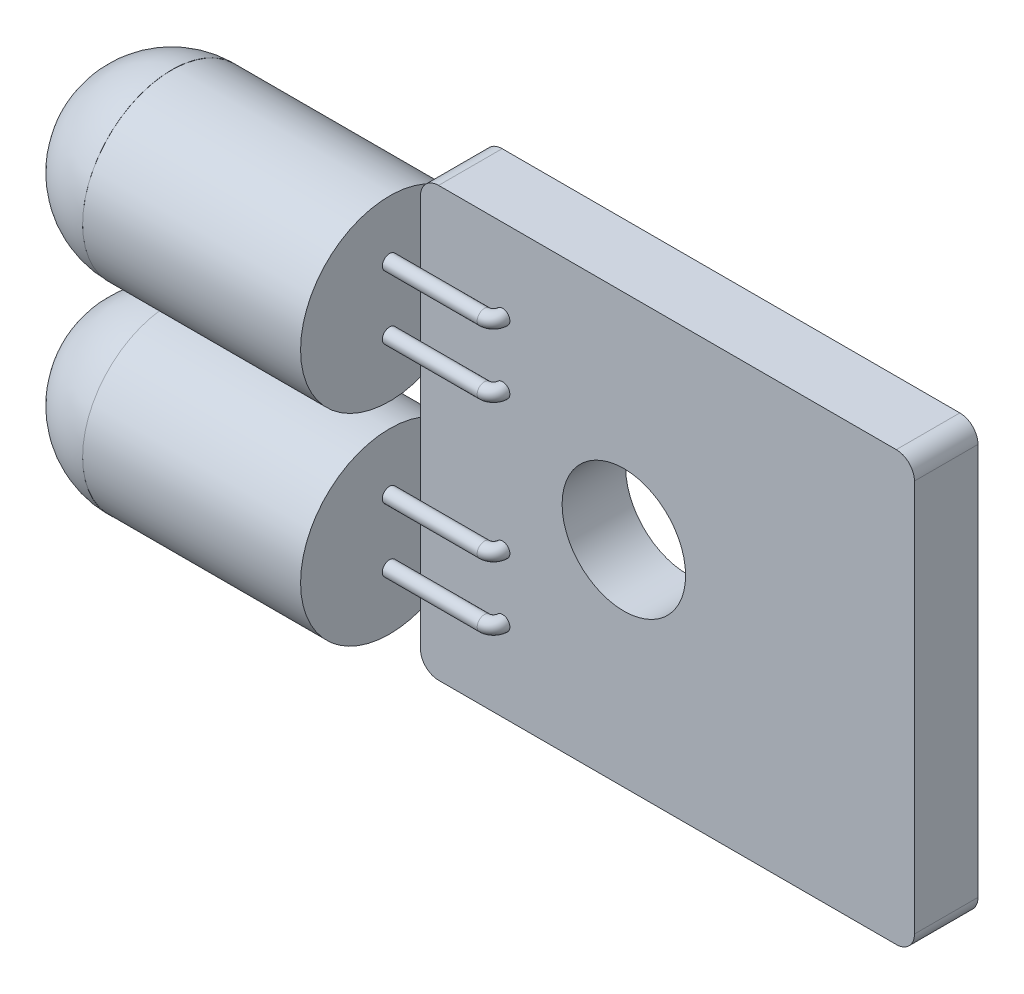
from build123d import *

# Parameters (mm, degrees)
SKETCH_1_W          = 13.6
SKETCH_1_H          = 11.8
EXTRUDE_1_DEPTH     = 1.75
SKETCH_3_R          = 2.45
EXTRUDE_11_DEPTH    = 6
EXTRUDE_11_2_DEPTH  = 6
CUT_EXTRUDE_1_DEPTH = 19.547304386
SWEEP_3_PROFILE_R   = 0.2
SWEEP_4_PROFILE_R   = 0.2
FILLET_1_R          = 0.5


with BuildPart() as part:
    # 草图1 → 凸台-拉伸1 (new body)
    with BuildSketch(Plane.XY):
        with Locations((6.8, -5.9)):
            Rectangle(SKETCH_1_W, SKETCH_1_H)
    extrude(amount=EXTRUDE_1_DEPTH)

    # 草图6 → 切除-拉伸1 (cut, through all)
    with BuildSketch(Plane(origin=(0, 0, 0), x_dir=(-1, 0, 0), z_dir=(0, 0, -1))):
        with BuildLine():
            ThreePointArc((-3.9, -5.9), (-4.397918472, -4.697918472), (-5.6, -4.2))
            Line((-5.6, -4.2), (-5.6, -7.6))
            ThreePointArc((-5.6, -7.6), (-4.397918472, -7.102081528), (-3.9, -5.9))
        make_face()
        with BuildLine():
            Line((-5.6, -7.6), (-5.6, -4.2))
            ThreePointArc((-5.6, -4.2), (-7.3, -5.9), (-5.6, -7.6))
        make_face()
    extrude(amount=-CUT_EXTRUDE_1_DEPTH, mode=Mode.SUBTRACT)

    # 扫描3: sweep along a path in 草图9
    with BuildLine(Plane(origin=(0, -4, 1.75), x_dir=(-1, 0, 0), z_dir=(0, -1, 0))) as sweep_3_path:
        Line((0.6, -0.25), (-2.012074207, -0.25))
        ThreePointArc((-2.012074207, -0.25), (-2.188850902, -0.176776695), (-2.262074207, 0))
    # 扫描3 profile (on start of the path) → 扫描3 (sweep)
    with BuildSketch(Plane(origin=(-0.6, -4, 2), x_dir=(0, 0, 1), z_dir=(1, 0, 0))):
        Circle(SWEEP_3_PROFILE_R)
    sweep_3 = sweep(path=sweep_3_path.line)

    # 扫描4: sweep along a path in 草图40
    with BuildLine(Plane(origin=(0, -2.25, 1.75), x_dir=(-1, 0, 0), z_dir=(0, -1, 0))) as sweep_4_path:
        Line((0.6, -0.25), (-2.012074207, -0.25))
        ThreePointArc((-2.012074207, -0.25), (-2.188850902, -0.176776695), (-2.262074207, 0))
    # 扫描4 profile (on start of the path) → 扫描4 (sweep)
    with BuildSketch(Plane(origin=(-0.6, -2.25, 2), x_dir=(0, 0, 1), z_dir=(1, 0, 0))):
        Circle(SWEEP_4_PROFILE_R)
    sweep_4 = sweep(path=sweep_4_path.line)


with BuildPart() as body_2:
    # 草图3 → 凸台-拉伸11 (new body)
    with BuildSketch(Plane.ZY.offset(0.6)):
        with Locations((2, -3.125)):
            Circle(SKETCH_3_R)
    extrude(amount=EXTRUDE_11_DEPTH)


with BuildPart() as body_3:
    # 草图3 → Extrude 11 2 (new body)
    with BuildSketch(Plane.ZY.offset(0.6)):
        with Locations((2, -8.675)):
            Circle(SKETCH_3_R)
    extrude(amount=EXTRUDE_11_2_DEPTH)


with BuildPart() as body_4:
    # 草图5 → 旋转1 (revolve)
    with BuildSketch(Plane(origin=(0, -3.12, 1.75), x_dir=(-1, 0, 0), z_dir=(0, -1, 0))):
        with BuildLine():
            Line((6.6, -0.25), (9.05, -0.25))
            ThreePointArc((9.05, -0.25), (8.332411614, 1.482411614), (6.6, 2.2))
            Line((6.6, 2.2), (6.6, -0.25))
        make_face()
    revolve_1 = revolve(axis=Axis((-6.6, -3.12, 2), (-1, 0, 0)))


with BuildPart() as part_1:
    add(part.part)

    add(body_3.part)  # 镜向1 merges body 3
    # 镜向1: 旋转1, 扫描3, 扫描4 across plane
    add(revolve_1.mirror(Plane(origin=(0, -5.9, 1.75), x_dir=(0, 0, 1), z_dir=(0, -1, 0))))
    add(sweep_3.mirror(Plane(origin=(0, -5.9, 1.75), x_dir=(0, 0, 1), z_dir=(0, -1, 0))))
    add(sweep_4.mirror(Plane(origin=(0, -5.9, 1.75), x_dir=(0, 0, 1), z_dir=(0, -1, 0))))

    # 圆角1
    fillet_1_edges = [part_1.edges().sort_by_distance(p)[0] for p in [
        (0, 0, 0.875),
        (0, -11.8, 0.875),
        (13.6, -11.8, 0.875),
        (13.6, 0, 0.875),
    ]]
    fillet(fillet_1_edges, radius=FILLET_1_R)


solid = Compound([body_2.part, body_4.part, part_1.part])
